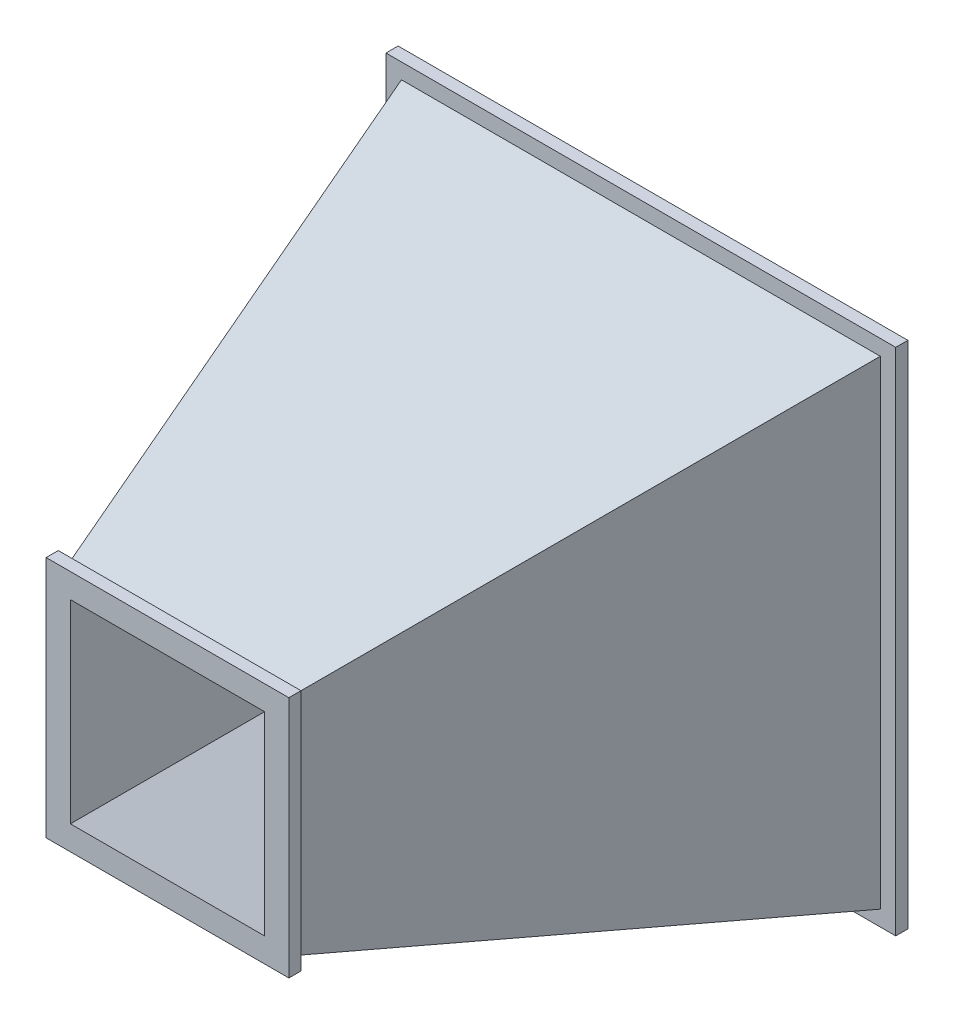
from build123d import *

# Parameters (mm, degrees)
SKETCH2_W           = 90
SKETCH2_H           = 90
SKETCH1_W           = 200
SKETCH1_H           = 200
SKETCH6_W           = 210
SKETCH6_H           = 210
BOSS_EXTRUDE1_DEPTH = 5
SKETCH5_W           = 100
SKETCH5_H           = 100
BOSS_EXTRUDE2_DEPTH = 5
SKETCH3_W           = 80
SKETCH3_H           = 80
SKETCH4_W           = 190
SKETCH4_H           = 190


with BuildPart() as part:
    # Sketch2 → Loft2 section 0
    with BuildSketch(Plane.XY.offset(200)):
        Rectangle(SKETCH2_W, SKETCH2_H)
    # Sketch1 → Loft2 section 1
    with BuildSketch(Plane.XY):
        Rectangle(SKETCH1_W, SKETCH1_H)
    loft()

    # Sketch6 → Boss-Extrude1 (add)
    with BuildSketch(Plane(origin=(0, 0, 0), x_dir=(-1, 0, 0), z_dir=(0, 0, -1))):
        Rectangle(SKETCH6_W, SKETCH6_H)
    extrude(amount=-BOSS_EXTRUDE1_DEPTH)

    # Sketch5 → Boss-Extrude2 (add)
    with BuildSketch(Plane.XY.offset(200)):
        Rectangle(SKETCH5_W, SKETCH5_H)
    extrude(amount=-BOSS_EXTRUDE2_DEPTH)

    # Sketch3 → Cut-Loft2 section 0
    with BuildSketch(Plane.XY.offset(200)):
        Rectangle(SKETCH3_W, SKETCH3_H)
    # Sketch4 → Cut-Loft2 section 1
    with BuildSketch(Plane(origin=(0, 0, 0), x_dir=(-1, 0, 0), z_dir=(0, 0, -1))):
        Rectangle(SKETCH4_W, SKETCH4_H)
    loft(mode=Mode.SUBTRACT)


solid = part.part
